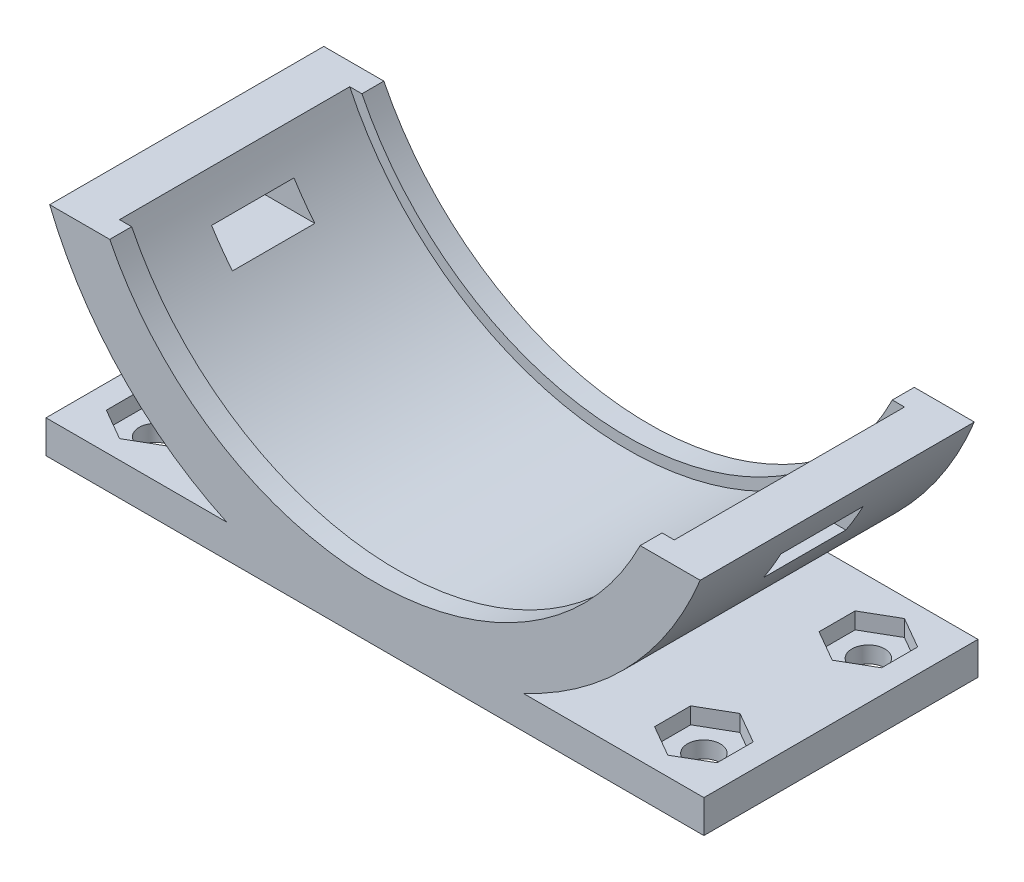
from build123d import *

# Parameters (mm, degrees)
EXTRUDE_1_DEPTH          = 25
SKETCH_2_W               = 7.514045852
SKETCH_2_H               = 2.645790793
CUT_EXTRUDE_1_DEPTH      = 109
CUT_EXTRUDE_1_DEPTH_BACK = 54
SKETCH_3_R               = 1.5
CUT_EXTRUDE_2_DEPTH      = 7
CUT_EXTRUDE_START        = -2
CUT_EXTRUDE_3_DEPTH      = 21
CUT_EXTRUDE_4_DEPTH      = 1.5


with BuildPart() as part:
    # 草图1 → 凸台-拉伸1 (new body)
    with BuildSketch(Plane.XY):
        with BuildLine():
            Line((30, -32), (-30, -32))
            Line((-30, -32), (-30, -29))
            Line((-30, -29), (-13.527749258, -29))
            ThreePointArc((-13.527749258, -29), (-23.208811843, -22.030684348), (-29.664793948, -12))
            Line((-29.664793948, -12), (-24.186773245, -12))
            ThreePointArc((-24.186773245, -12), (0, -27), (24.186773245, -12))
            Line((24.186773245, -12), (29.664793948, -12))
            ThreePointArc((29.664793948, -12), (23.208811843, -22.030684348), (13.527749258, -29))
            Line((13.527749258, -29), (30, -29))
            Line((30, -29), (30, -32))
        make_face()
    extrude(amount=EXTRUDE_1_DEPTH)

    # 草图2 → 切除-拉伸1 (cut, two sides)
    with BuildSketch(Plane(origin=(0, 0, 0), x_dir=(0, 0, -1), z_dir=(1, 0, 0))) as cut_extrude_1_sk:
        with Locations((-12.5, -16.322895397)):
            Rectangle(SKETCH_2_W, SKETCH_2_H)
    extrude(amount=CUT_EXTRUDE_1_DEPTH, mode=Mode.SUBTRACT)
    extrude(cut_extrude_1_sk.sketch, amount=-CUT_EXTRUDE_1_DEPTH_BACK, mode=Mode.SUBTRACT)

    # 草图3 → 切除-拉伸2 (cut)
    with BuildSketch(Plane.XZ.offset(32)):
        with Locations((-25, 20)):
            Circle(SKETCH_3_R)
        with Locations((25, 20)):
            Circle(SKETCH_3_R)
        with Locations((25, 5)):
            Circle(SKETCH_3_R)
        with Locations((-25, 5)):
            Circle(SKETCH_3_R)
    extrude(amount=-CUT_EXTRUDE_2_DEPTH, mode=Mode.SUBTRACT)

    # 草图4 → 切除-拉伸3 (cut)
    with BuildSketch(Plane.XY.offset(25).offset(CUT_EXTRUDE_START)):
        with BuildLine():
            Line((24.186773245, -12), (25.298221281, -12))
            ThreePointArc((25.298221281, -12), (0, -28), (-25.298221281, -12))
            Line((-25.298221281, -12), (-24.186773245, -12))
            ThreePointArc((-24.186773245, -12), (0, -27), (24.186773245, -12))
        make_face()
    extrude(amount=-CUT_EXTRUDE_3_DEPTH, mode=Mode.SUBTRACT)

    # 草图5 → 切除-拉伸4 (cut)
    with BuildSketch(Plane(origin=(0, -29, 0), x_dir=(1, 0, 0), z_dir=(0, 1, 0))):
        Polygon((-25, -23.290896534), (-22.15, -21.645448267), (-22.15, -18.354551733), (-25, -16.709103466), (-27.85, -18.354551733), (-27.85, -21.645448267), align=None)
        Polygon((27.85, -21.645448267), (25, -23.290896534), (22.15, -21.645448267), (22.15, -18.354551733), (25, -16.709103466), (27.85, -18.354551733), align=None)
        Polygon((25, -1.709103466), (22.15, -3.354551733), (22.15, -6.645448267), (25, -8.290896534), (27.85, -6.645448267), (27.85, -3.354551733), align=None)
        Polygon((-27.85, -3.354551733), (-25, -1.709103466), (-22.15, -3.354551733), (-22.15, -6.645448267), (-25, -8.290896534), (-27.85, -6.645448267), align=None)
    extrude(amount=-CUT_EXTRUDE_4_DEPTH, mode=Mode.SUBTRACT)


solid = part.part
